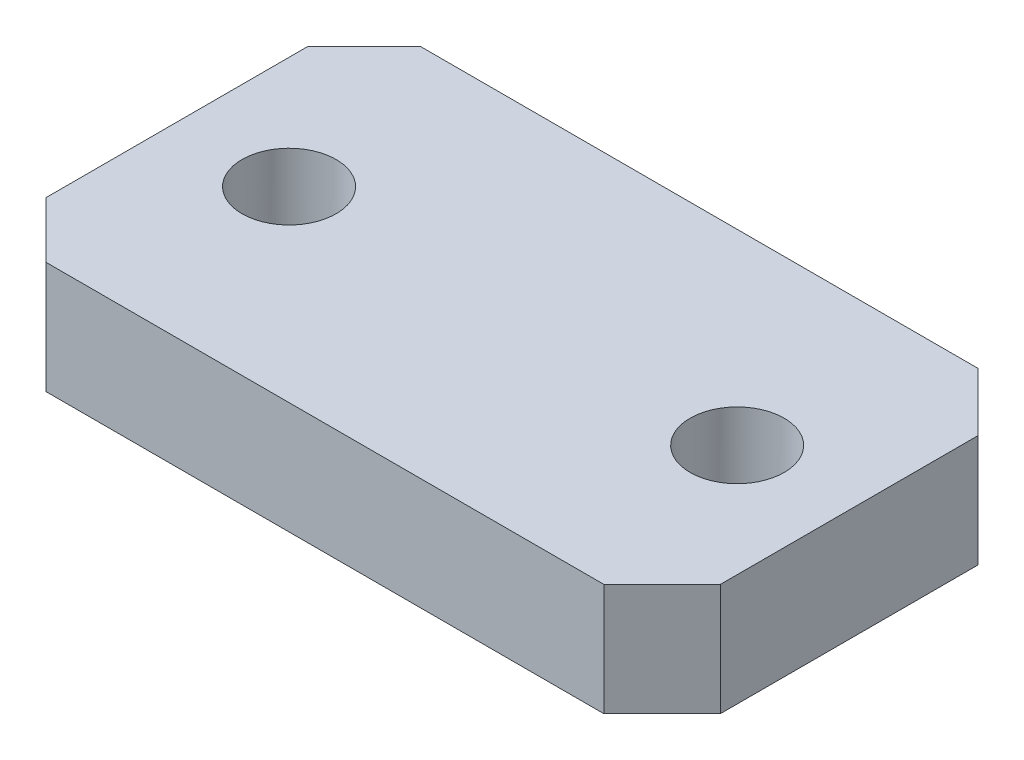
from build123d import *

# Parameters (mm, degrees)
SKETCH1_W           = 38.1
SKETCH1_H           = 21.209
BOSS_EXTRUDE1_DEPTH = 6.35
SKETCH2_R           = 2.667
CUT_EXTRUDE1_DEPTH  = 9.525
CUT_EXTRUDE2_DEPTH  = 9.525


with BuildPart() as part:
    # Sketch1 → Boss-Extrude1 (new body)
    with BuildSketch(Plane(origin=(0, 0, 0), x_dir=(1, 0, 0), z_dir=(0, 1, 0))):
        Rectangle(SKETCH1_W, SKETCH1_H)
    extrude(amount=BOSS_EXTRUDE1_DEPTH)

    # Sketch2 → Cut-Extrude1 (cut)
    with BuildSketch(Plane(origin=(0, 6.35, 0), x_dir=(1, 0, 0), z_dir=(0, 1, 0))):
        with Locations((-12.7, 0)):
            Circle(SKETCH2_R)
        with Locations((12.7, 0)):
            Circle(SKETCH2_R)
    extrude(amount=-CUT_EXTRUDE1_DEPTH, mode=Mode.SUBTRACT)

    # Sketch3 → Cut-Extrude2 (cut)
    with BuildSketch(Plane(origin=(0, 6.35, 0), x_dir=(1, 0, 0), z_dir=(0, 1, 0))):
        Polygon((-19.05, 10.6045), (-15.875, 10.6045), (-19.05, 7.4295), align=None)
        Polygon((19.05, 10.6045), (15.748, 10.6045), (19.05, 7.3025), align=None)
        Polygon((19.05, -10.6045), (15.748, -10.6045), (19.05, -7.3025), align=None)
        Polygon((-19.05, -10.6045), (-15.875, -10.6045), (-19.05, -7.4295), align=None)
    extrude(amount=-CUT_EXTRUDE2_DEPTH, mode=Mode.SUBTRACT)


solid = part.part
